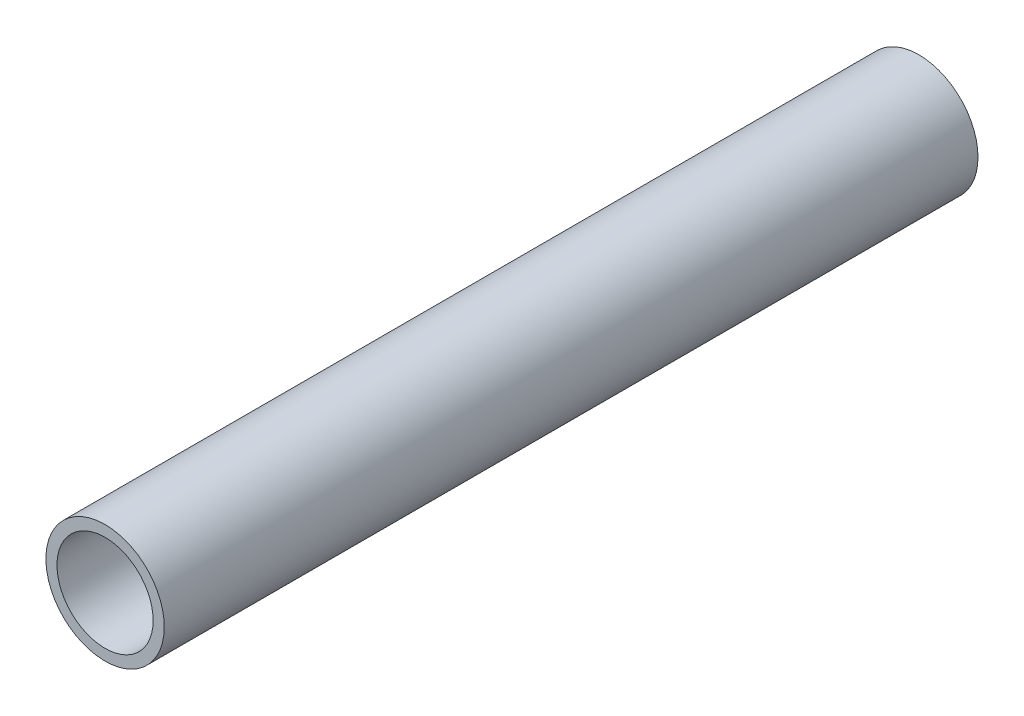
from build123d import *

# Parameters (mm, degrees)
CROQUIS1_R              = 4
CROQUIS1_R_2            = 3.25
SALIENTE_EXTRUIR1_DEPTH = 55


with BuildPart() as part:
    # Croquis1 → Saliente-Extruir1 (new body)
    with BuildSketch(Plane.XY):
        Circle(CROQUIS1_R)
        Circle(CROQUIS1_R_2, mode=Mode.SUBTRACT)
    extrude(amount=SALIENTE_EXTRUIR1_DEPTH)


solid = part.part
